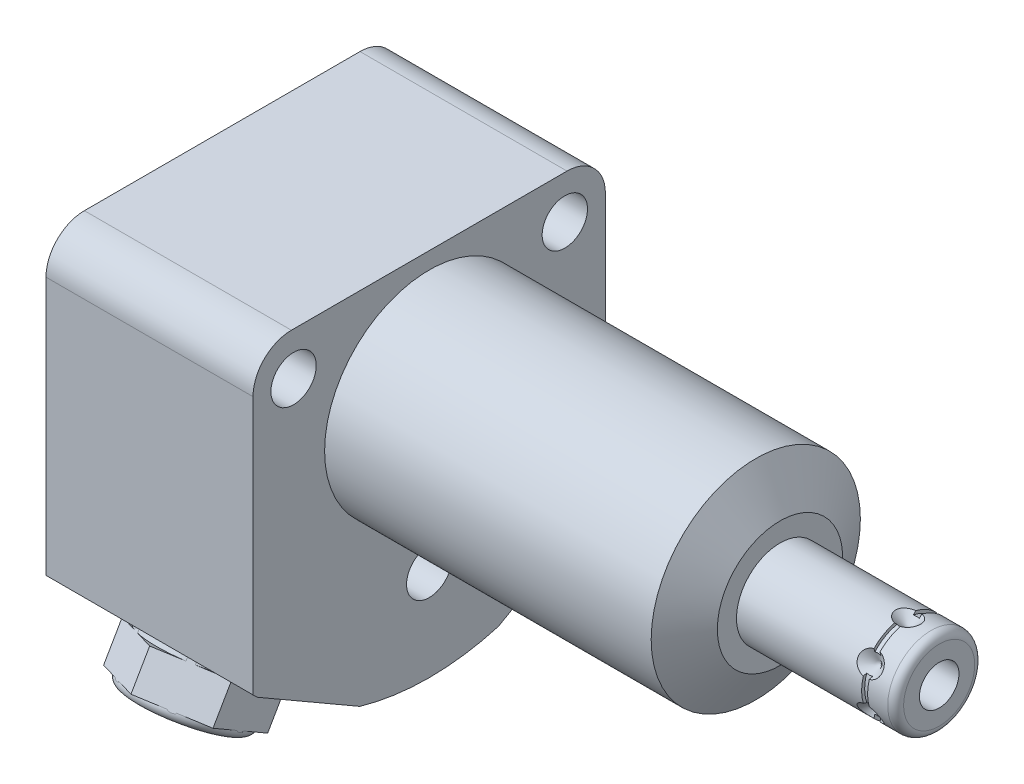
from build123d import *

# Parameters (mm, degrees)
EXTRUDE1_DEPTH           = 44.8056
EXTRUDE1_DEPTH_BACK      = 26.4414
CUT_EXTRUDE1_REACH       = 46.806
SKETCH2_R                = 13.3604
SKETCH11_W               = 0.762
SKETCH11_H               = 0.381
EXTRUDE2_DEPTH           = 6.78
SKETCH13_W               = 1
SKETCH13_H               = 1.25
SKETCH15_R               = 2.7432
EXTRUDE3_DEPTH           = 2.9972
CUT_EXTRUDE2_DEPTH       = 2.54
CHAMFER1_SIZE            = 0.381
CHAMFER1_OF_MIRROR2_SIZE = 0.381
SKETCH21_R               = 0.889
FILLET1_R                = 4.9022
SKETCH22_W               = 2.8955
SKETCH22_H               = 26.4414
HOLE1_AT_2_COUNT         = 2
HOLE1_AT_2_PITCH         = 34.639910603
HOLE1_AT_3_COUNT         = 2
HOLE1_AT_3_PITCH         = 34.639910603
CIRPATTERN1_COUNT        = 6


with BuildPart() as part:
    # Sketch1 → Extrude1 (new body, two sides)
    with BuildSketch(Plane(origin=(0, 0, 0), x_dir=(0, 0, -1), z_dir=(1, 0, 0))) as extrude1_sk:
        with BuildLine():
            Line((-22.5044, 15.494), (-22.5044, -22.396751564))
            ThreePointArc((-22.5044, -22.396751564), (-22.237765115, -22.661515896), (-21.968015496, -22.923106141))
            Line((-21.968015496, -22.923106141), (-8.867984504, -30.486412561))
            ThreePointArc((-8.867984504, -30.486412561), (0, -31.75), (8.867984504, -30.486412561))
            Line((8.867984504, -30.486412561), (21.968015496, -22.923106141))
            ThreePointArc((21.968015496, -22.923106141), (22.237765115, -22.661515896), (22.5044, -22.396751564))
            Line((22.5044, -22.396751564), (22.5044, 15.494))
            Line((22.5044, 15.494), (-22.5044, 15.494))
        make_face()
    extrude(amount=EXTRUDE1_DEPTH)
    extrude(extrude1_sk.sketch, amount=-EXTRUDE1_DEPTH_BACK)

    # Sketch2 → Cut-Extrude1 (cut, up to next)
    with BuildSketch(Plane(origin=(0, 0, 0), x_dir=(0, 0, -1), z_dir=(1, 0, 0)), mode=Mode.PRIVATE) as cut_extrude1_sk1:
        with BuildLine():
            Line((22.5044, 15.494), (-22.5044, 15.494))
            Line((-22.5044, 15.494), (-22.5044, -22.396751564))
            ThreePointArc((-22.5044, -22.396751564), (-22.237765115, -22.661515896), (-21.968015496, -22.923106141))
            Line((-21.968015496, -22.923106141), (-8.867984504, -30.486412561))
            ThreePointArc((-8.867984504, -30.486412561), (0, -31.75), (8.867984504, -30.486412561))
            Line((8.867984504, -30.486412561), (21.968015496, -22.923106141))
            ThreePointArc((21.968015496, -22.923106141), (22.237765115, -22.661515896), (22.5044, -22.396751564))
            Line((22.5044, -22.396751564), (22.5044, 15.494))
        make_face()
        Circle(SKETCH2_R, mode=Mode.SUBTRACT)
    cut_extrude1_tool1 = extrude(cut_extrude1_sk1.sketch, amount=CUT_EXTRUDE1_REACH, mode=Mode.PRIVATE) & part.part
    add(cut_extrude1_tool1.solids().sort_by_distance((0, -3.451376, -21.851883))[0], mode=Mode.SUBTRACT)

    # Sketch3 → Cut-Revolve1 (revolve, cut)
    with BuildSketch(Plane.XY, mode=Mode.PRIVATE) as cut_revolve1_sk:
        Polygon((41.711348967, 13.3604), (44.8056, 8.001), (44.8056, 13.3604), align=None)
    revolve(cut_revolve1_sk.sketch.rotate(Axis((23.304450239, 0, 0), (1, 0, 0)), 90), axis=Axis((23.304450239, 0, 0), (1, 0, 0)), mode=Mode.SUBTRACT)  # turned: the seam where the file's is

    # S2D0002 → Cut-Revolve2 (revolve, cut)
    with BuildSketch(Plane(origin=(-24.9936, -18.1864, 10.49), x_dir=(0, 1, 0), z_dir=(0, 0, 1)), mode=Mode.PRIVATE) as cut_revolve2_sk:
        Polygon((3.2512, 0), (5.7023, 0), (5.7023, 1.4478), (0, 1.4478), (0, -11.9888), (1.2446, -11.9888), (1.2446, -2.9972), (3.2512, -2.9972), align=None)
    cut_revolve2 = revolve(cut_revolve2_sk.sketch.rotate(Axis((-1.435104963, -18.1864, 10.49), (-1, 0, 0)), 90), axis=Axis((-1.435104963, -18.1864, 10.49), (-1, 0, 0)), mode=Mode.SUBTRACT)  # turned: the seam where the file's is

    # Sketch6 → Cut-Revolve4 (revolve, cut)
    with BuildSketch(Plane(origin=(-12.9286, 0, 0), x_dir=(0, 0, -1), z_dir=(1, 0, 0)), mode=Mode.PRIVATE) as cut_revolve4_sk:
        Polygon((-19.580423825, -24.008288899), (-22.435709581, -22.359788899), (-22.562709581, -22.579759351), (-15.418, -26.704759351), (-10.0078, -17.334018072), (-13.835285875, -15.124218072), (-18.788285875, -23.703065722), (-19.516923825, -23.898303672), align=None)
    cut_revolve4 = revolve(cut_revolve4_sk.sketch.rotate(Axis((-12.9286, -11.344731937, 6.549884038), (0, 0.866025404, -0.5)), 180), axis=Axis((-12.9286, -11.344731937, 6.549884038), (0, 0.866025404, -0.5)), mode=Mode.SUBTRACT)  # turned: the seam where the file's is

    # Mirror1: Cut-Revolve2, Cut-Revolve4 across plane
    add(cut_revolve2.mirror(Plane.XY), mode=Mode.SUBTRACT)
    add(cut_revolve4.mirror(Plane.XY), mode=Mode.SUBTRACT)

    # Sketch7 → Revolve1 (revolve)
    with BuildSketch(Plane.XY, mode=Mode.PRIVATE) as revolve1_sk:
        with BuildLine():
            Line((44.8056, 0), (44.8056, 5.55625))
            Line((44.8056, 5.55625), (64.1226, 5.55625))
            ThreePointArc((64.1226, 5.55625), (64.84102049, 5.25867049), (65.1386, 4.54025))
            Line((65.1386, 4.54025), (65.1386, 0))
            Line((65.1386, 0), (44.8056, 0))
        make_face()
    revolve(revolve1_sk.sketch.rotate(Axis((4.993122661, 0, 0), (1, 0, 0)), 90), axis=Axis((4.993122661, 0, 0), (1, 0, 0)))  # turned: the seam where the file's is

    # S2D0001 → Cut-Revolve8 (revolve, cut)
    with BuildSketch(Plane.XY, mode=Mode.PRIVATE) as cut_revolve8_sk:
        Polygon((65.1386, -2.5273), (54.9786, -2.5273), (53.460044958, 0), (65.1386, 0), align=None)
    revolve(cut_revolve8_sk.sketch.rotate(Axis((-2.5273, 0, 0), (-1, 0, 0)), 90), axis=Axis((-2.5273, 0, 0), (-1, 0, 0)), mode=Mode.SUBTRACT)  # turned: the seam where the file's is

    # Sketch9 → Cut-Revolve9 (revolve, cut)
    with BuildSketch(Plane.XY, mode=Mode.PRIVATE) as cut_revolve9_sk:
        Polygon((61.1762, -5.55625), (59.5887, -5.55625), (61.1762, -3.96875), align=None)
    cut_revolve9 = revolve(cut_revolve9_sk.sketch.rotate(Axis((61.1762, -6.253416753, 0), (0, 1, 0)), 270), axis=Axis((61.1762, -6.253416753, 0), (0, 1, 0)), mode=Mode.SUBTRACT)  # turned: the seam where the file's is

    # Sketch11 → Cut-Revolve5 (revolve, cut)
    with BuildSketch(Plane(origin=(0, 0, 0), x_dir=(1, 0, 0), z_dir=(0, 1, 0))):
        with Locations((61.1762, -5.36575)):
            Rectangle(SKETCH11_W, SKETCH11_H)
    revolve(axis=Axis((0, 0, 0), (1, 0, 0)), mode=Mode.SUBTRACT)

    # Sketch12 → Extrude2 (add)
    with BuildSketch(Plane(origin=(0, -26.484788899, 15.291), x_dir=(1, 0, 0), z_dir=(0, -0.866025404, 0.5))):
        Polygon((-12.9286, -8.065583261), (-5.9436, -4.03279163), (-5.9436, 4.03279163), (-12.9286, 8.065583261), (-19.9136, 4.03279163), (-19.9136, -4.03279163), align=None)
    extrude(amount=EXTRUDE2_DEPTH)

    # Sketch13 → Cut-Revolve6 (revolve, cut)
    with BuildSketch(Plane(origin=(-12.9286, -6.4643, -11.196496035), x_dir=(0, -0.866025404, 0.5), z_dir=(1, 0, 0))):
        with Locations((31.082, -5.3036)):
            Rectangle(SKETCH13_W, SKETCH13_H)
        with BuildLine():
            Line((36.362, -5.9286), (36.362, -4.6786))
            Line((36.362, -4.6786), (37.362, -4.6786))
            Line((37.362, -4.6786), (37.362, -6.9286))
            ThreePointArc((37.362, -6.9286), (37.069106781, -6.221493219), (36.362, -5.9286))
        make_face()
    revolve(axis=Axis((-12.9286, -26.051776197, 15.041), (0, -0.866025404, 0.5)), mode=Mode.SUBTRACT)

    # Sketch15 → Extrude3 (add)
    with BuildSketch(Plane.ZY.offset(21.9964)):
        with Locations(Location((10.49, -18.1864, 0), (0, 0, 180))):  # turned: the seam where the file's is
            Circle(SKETCH15_R)
    extrude3 = extrude(amount=EXTRUDE3_DEPTH)

    # Sketch16 → Cut-Extrude2 (cut)
    with BuildSketch(Plane.ZY.offset(24.9936)):
        Polygon((11.92714029, -18.1864), (11.208570145, -16.9418), (9.771429855, -16.9418), (9.05285971, -18.1864), (9.771429855, -19.431), (11.208570145, -19.431), align=None)
    cut_extrude2 = extrude(amount=-CUT_EXTRUDE2_DEPTH, mode=Mode.SUBTRACT)

    # Chamfer1
    chamfer1_edges = [part.edges().sort_by_distance(p)[0] for p in [
        (-24.9936, -18.1864, 13.2332),
    ]]
    chamfer(chamfer1_edges, length=CHAMFER1_SIZE)

    # Mirror2: Extrude3, Cut-Extrude2 across plane
    add(extrude3.mirror(Plane.XY))
    add(cut_extrude2.mirror(Plane.XY), mode=Mode.SUBTRACT)

    # Chamfer1 of Mirror2
    chamfer1_of_mirror2_edges = [part.edges().sort_by_distance(p)[0] for p in [
        (-24.9936, -18.1864, -13.2332),
    ]]
    chamfer(chamfer1_of_mirror2_edges, length=CHAMFER1_OF_MIRROR2_SIZE)

    # Fillet1
    fillet1_edges = [part.edges().sort_by_distance(p)[0] for p in [
        (-13.2207, 15.494, -22.5044),
        (-13.2207, 15.494, 22.5044),
    ]]
    fillet(fillet1_edges, radius=FILLET1_R)

    # Sketch22 → Hole1 (revolve, cut)
    with BuildSketch(Plane(origin=(0, -19.9898, 0), x_dir=(0, 0, -1), z_dir=(0, 1, 0))):
        with Locations((1.44775, 13.2207)):
            Rectangle(SKETCH22_W, SKETCH22_H)
    hole1 = revolve(axis=Axis((-110, -19.9898, 0), (1, 0, 0)), mode=Mode.SUBTRACT)

    # Hole1 at 2: Hole1 ×2
    with Locations(*[Vector(0, 0.865977985, 0.500082122) * (i * HOLE1_AT_2_PITCH) for i in range(1, HOLE1_AT_2_COUNT)]):
        add(hole1, mode=Mode.SUBTRACT)

    # Hole1 at 3: Hole1 ×2
    with Locations(*[Vector(0, 0.865977985, -0.500082122) * (i * HOLE1_AT_3_PITCH) for i in range(1, HOLE1_AT_3_COUNT)]):
        add(hole1, mode=Mode.SUBTRACT)

    # CirPattern1: Cut-Revolve9 ×6 about axis
    cirpattern1_axis = Axis((0, 0, 0), (1, 0, 0))
    for i in range(1, CIRPATTERN1_COUNT):
        add(cut_revolve9.rotate(cirpattern1_axis, i * 360 / CIRPATTERN1_COUNT), mode=Mode.SUBTRACT)


with BuildPart() as body_2:
    # Sketch21 → Revolve4 (revolve)
    with BuildSketch(Plane.XY.offset(10.49), mode=Mode.PRIVATE) as revolve4_sk:
        with Locations((-25.8572, -13.3731)):
            Circle(SKETCH21_R)
    revolve(revolve4_sk.sketch.rotate(Axis((-35.974373203, -18.1864, 10.49), (1, 0, 0)), 270), axis=Axis((-35.974373203, -18.1864, 10.49), (1, 0, 0)))  # turned: the seam where the file's is


with BuildPart() as body_3:
    # Mirror3: mirrored copy
    add(body_2.part.mirror(Plane.XY))


solid = Compound([part.part, body_2.part, body_3.part])
